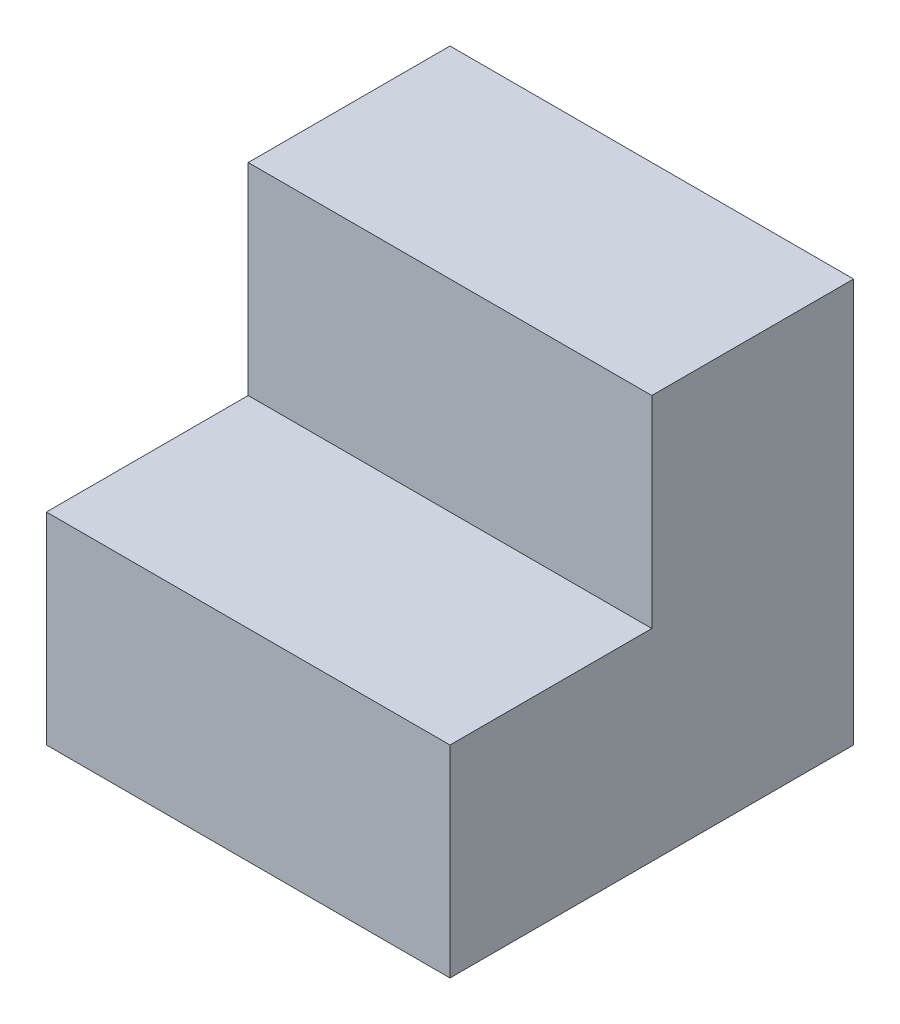
from build123d import *

# Parameters (mm, degrees)
AUFSATZ_LINEAR_AUSTRAGEN1_DEPTH = 0.5


with BuildPart() as part:
    # Skizze1 → Aufsatz-Linear austragen1 (new body, symmetric)
    with BuildSketch(Plane(origin=(0, 0, 0), x_dir=(0, 0, -1), z_dir=(1, 0, 0))):
        Polygon((0, 0), (0, 0.5), (0.5, 0.5), (0.5, -0.5), (-0.5, -0.5), (-0.5, 0), align=None)
    extrude(amount=AUFSATZ_LINEAR_AUSTRAGEN1_DEPTH, both=True)


solid = part.part
